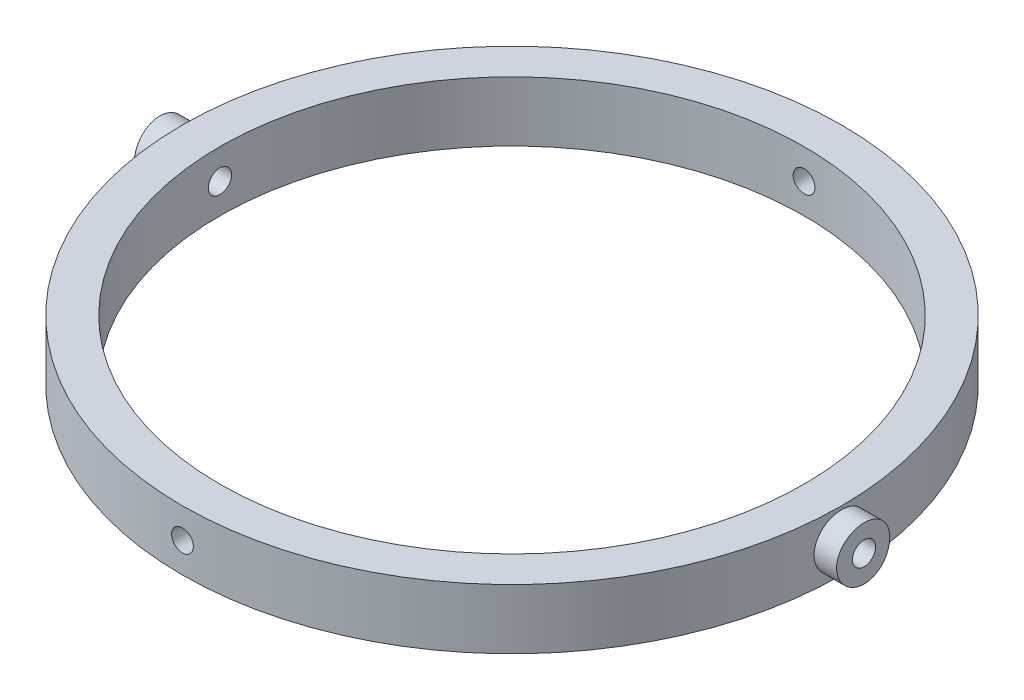
from build123d import *

# Parameters (mm, degrees)
SKETCH1_R               = 44
SKETCH1_R_2             = 39
BOSS_EXTRUDE1_DEPTH     = 8
SKETCH2_R               = 1.45
CUT_EXTRUDE1_DEPTH      = 45
CUT_EXTRUDE1_DEPTH_BACK = 45
SKETCH3_R               = 1.55
CUT_EXTRUDE2_DEPTH      = 45.0000001
CUT_EXTRUDE2_DEPTH_BACK = 45.0000001
BOSS_EXTRUDE2_START     = -3.143444
SKETCH4_R               = 3.55
SKETCH4_R_2             = 1.55
BOSS_EXTRUDE2_DEPTH     = 3.143444
SKETCH7_R               = 50
SKETCH7_R_2             = 47
CUT_EXTRUDE3_DEPTH      = 9.0000001


with BuildPart() as part:
    # Sketch1 → Boss-Extrude1 (new body)
    with BuildSketch(Plane(origin=(0, 0, 0), x_dir=(1, 0, 0), z_dir=(0, 1, 0))):
        Circle(SKETCH1_R)
        Circle(SKETCH1_R_2, mode=Mode.SUBTRACT)
    extrude(amount=BOSS_EXTRUDE1_DEPTH)

    # Sketch2 → Cut-Extrude1 (cut, two sides)
    with BuildSketch(Plane.XY) as cut_extrude1_sk:
        with Locations((0, 4)):
            Circle(SKETCH2_R)
    extrude(amount=CUT_EXTRUDE1_DEPTH, mode=Mode.SUBTRACT)
    extrude(cut_extrude1_sk.sketch, amount=-CUT_EXTRUDE1_DEPTH_BACK, mode=Mode.SUBTRACT)

    # Sketch3 → Cut-Extrude2 (cut, two sides)
    with BuildSketch(Plane(origin=(0, 0, 0), x_dir=(0, 0, -1), z_dir=(1, 0, 0))) as cut_extrude2_sk:
        with Locations((0, 4)):
            Circle(SKETCH3_R)
    extrude(amount=CUT_EXTRUDE2_DEPTH, mode=Mode.SUBTRACT)
    extrude(cut_extrude2_sk.sketch, amount=-CUT_EXTRUDE2_DEPTH_BACK, mode=Mode.SUBTRACT)

    # Sketch4 → Boss-Extrude2 (add)
    with BuildSketch(Plane(origin=(47, 0, 0), x_dir=(0, 0, -1), z_dir=(1, 0, 0)).offset(BOSS_EXTRUDE2_START)):
        with Locations((0, 4)):
            Circle(SKETCH4_R)
        with Locations((0, 4)):
            Circle(SKETCH4_R_2, mode=Mode.SUBTRACT)
    boss_extrude2 = extrude(amount=BOSS_EXTRUDE2_DEPTH)

    # Mirror1: Boss-Extrude2 across plane
    add(boss_extrude2.mirror(Plane(origin=(0, 0, 0), x_dir=(0, 0, 1), z_dir=(1, 0, 0))))

    # Sketch7 → Cut-Extrude3 (cut, through all)
    with BuildSketch(Plane(origin=(0, 8, 0), x_dir=(1, 0, 0), z_dir=(0, 1, 0))):
        Circle(SKETCH7_R)
        Circle(SKETCH7_R_2, mode=Mode.SUBTRACT)
    extrude(amount=-CUT_EXTRUDE3_DEPTH, mode=Mode.SUBTRACT)


solid = part.part
